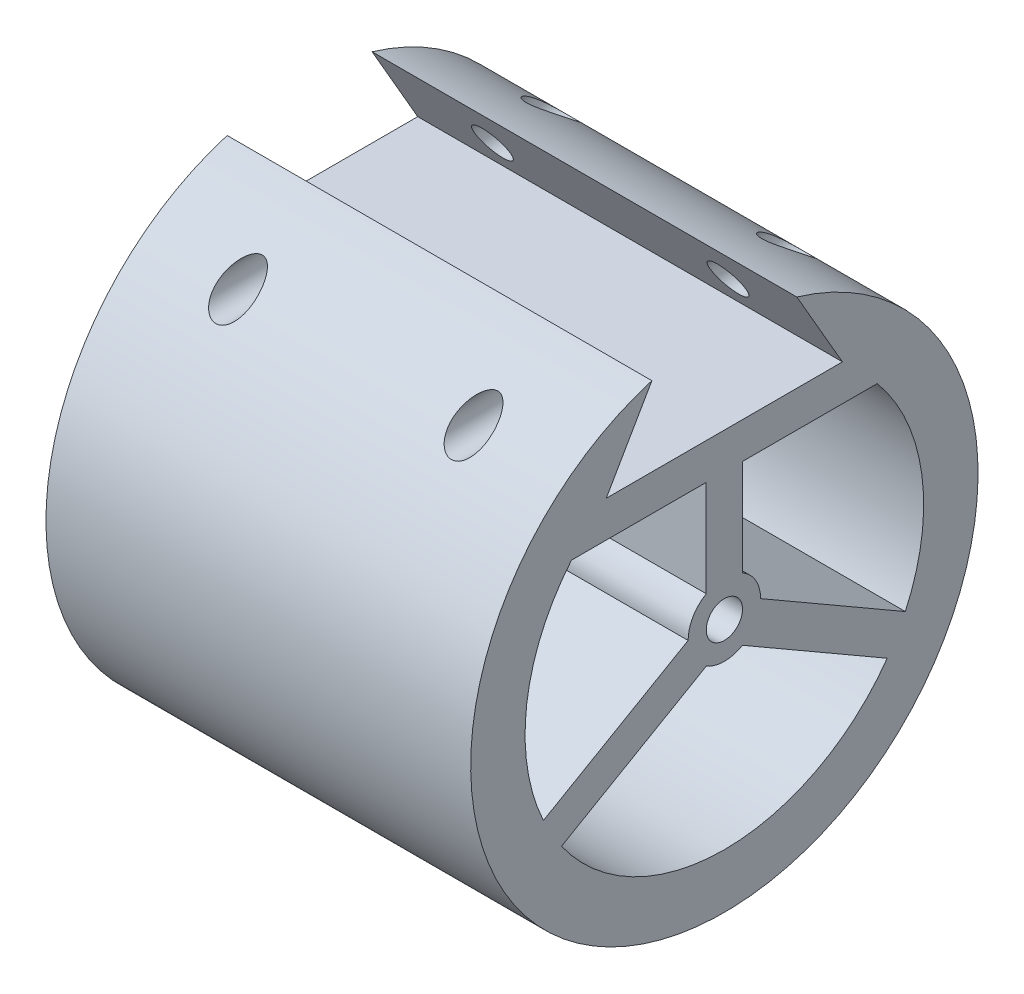
from build123d import *

# Parameters (mm, degrees)
SKETCH1_R                = 14
SKETCH1_R_2              = 11
BOSS_EXTRUDE1_DEPTH      = 11.72
BOSS_EXTRUDE1_DEPTH_BACK = 11.72
CUT_EXTRUDE1_DEPTH       = 12.72
CUT_EXTRUDE1_DEPTH_BACK  = 12.72
BOSS_EXTRUDE2_START      = -11.72
SKETCH3_R                = 1
BOSS_EXTRUDE2_DEPTH      = 23.44
SKETCH4_R                = 1
CUT_EXTRUDE2_DEPTH       = 15
CUT_EXTRUDE2_DEPTH_BACK  = 15


with BuildPart() as part:
    # Sketch1 → Boss-Extrude1 (new body, two sides)
    with BuildSketch(Plane(origin=(0, 0, 0), x_dir=(0, 0, -1), z_dir=(1, 0, 0))) as boss_extrude1_sk:
        Circle(SKETCH1_R)
        Circle(SKETCH1_R_2, mode=Mode.SUBTRACT)
    extrude(amount=BOSS_EXTRUDE1_DEPTH)
    extrude(boss_extrude1_sk.sketch, amount=-BOSS_EXTRUDE1_DEPTH_BACK)

    # Sketch2 → Cut-Extrude1 (cut, two sides)
    with BuildSketch(Plane(origin=(0, 0, 0), x_dir=(0, 0, -1), z_dir=(1, 0, 0))) as cut_extrude1_sk:
        with BuildLine():
            Line((-6.517247174, 9.056407865), (6.517247174, 9.056407865))
            Line((6.517247174, 9.056407865), (4, 13.416407865))
            ThreePointArc((4, 13.416407865), (0, 14), (-4, 13.416407865))
            Line((-4, 13.416407865), (-6.517247174, 9.056407865))
        make_face()
    extrude(amount=CUT_EXTRUDE1_DEPTH, mode=Mode.SUBTRACT)
    extrude(cut_extrude1_sk.sketch, amount=-CUT_EXTRUDE1_DEPTH_BACK, mode=Mode.SUBTRACT)

    # Sketch3 → Boss-Extrude2 (add)
    with BuildSketch(Plane(origin=(0, 0, 0), x_dir=(0, 0, -1), z_dir=(1, 0, 0)).offset(BOSS_EXTRUDE2_START)):
        with BuildLine():
            Line((-12.593386622, -6.116094618), (-11.593386622, -7.848145426))
            Line((-11.593386622, -7.848145426), (-1, -1.732050808))
            ThreePointArc((-1, -1.732050808), (0, -2), (1, -1.732050808))
            Line((1, -1.732050808), (11.593386622, -7.848145426))
            Line((11.593386622, -7.848145426), (12.593386622, -6.116094618))
            Line((12.593386622, -6.116094618), (2, 0))
            ThreePointArc((2, 0), (1.732050808, 1), (1, 1.732050808))
            Line((1, 1.732050808), (1, 7.056407865))
            Line((1, 7.056407865), (8.438430425, 7.056407865))
            Line((8.438430425, 7.056407865), (8.438430425, 9.056407865))
            Line((8.438430425, 9.056407865), (-8.438430425, 9.056407865))
            Line((-8.438430425, 9.056407865), (-8.438430425, 7.056407865))
            Line((-8.438430425, 7.056407865), (-1, 7.056407865))
            Line((-1, 7.056407865), (-1, 1.732050808))
            ThreePointArc((-1, 1.732050808), (-1.732050808, 1), (-2, 0))
            Line((-2, 0), (-12.593386622, -6.116094618))
        make_face()
        Circle(SKETCH3_R, mode=Mode.SUBTRACT)
    extrude(amount=BOSS_EXTRUDE2_DEPTH)

    # Sketch4 → Cut-Extrude2 (cut, two sides)
    with BuildSketch(Plane.XY) as cut_extrude2_sk:
        with Locations((-6.5, 10.956407865)):
            Circle(SKETCH4_R)
        with Locations((6.5, 10.956407865)):
            Circle(SKETCH4_R)
    extrude(amount=CUT_EXTRUDE2_DEPTH, mode=Mode.SUBTRACT)
    extrude(cut_extrude2_sk.sketch, amount=-CUT_EXTRUDE2_DEPTH_BACK, mode=Mode.SUBTRACT)


solid = part.part
